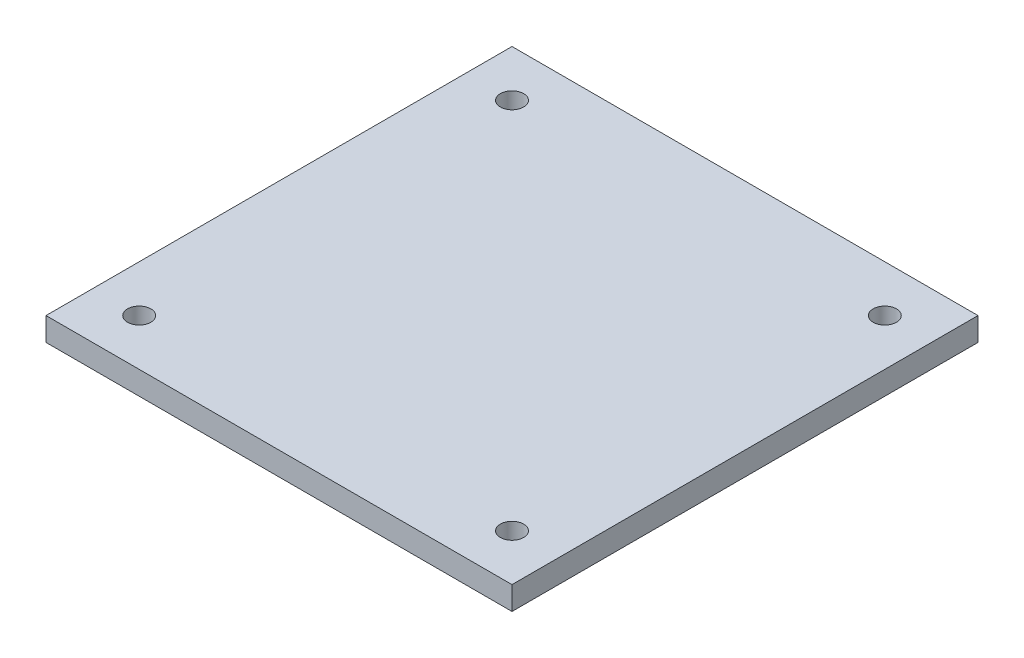
from build123d import *

# Parameters (mm, degrees)
SKETCH1_W           = 200
SKETCH1_H           = 200
BOSS_EXTRUDE1_DEPTH = 10
SKETCH2_R           = 5
CUT_EXTRUDE1_DEPTH  = 10


with BuildPart() as part:
    # Sketch1 → Boss-Extrude1 (new body)
    with BuildSketch(Plane(origin=(0, 0, 0), x_dir=(1, 0, 0), z_dir=(0, 1, 0))):
        Rectangle(SKETCH1_W, SKETCH1_H)
    extrude(amount=BOSS_EXTRUDE1_DEPTH)

    # Sketch2 → Cut-Extrude1 (cut)
    with BuildSketch(Plane(origin=(0, 10, 0), x_dir=(1, 0, 0), z_dir=(0, 1, 0))):
        with Locations((-80, 80)):
            Circle(SKETCH2_R)
        with Locations((80, 80)):
            Circle(SKETCH2_R)
        with Locations((80, -80)):
            Circle(SKETCH2_R)
        with Locations((-80, -80)):
            Circle(SKETCH2_R)
    extrude(amount=-CUT_EXTRUDE1_DEPTH, mode=Mode.SUBTRACT)


solid = part.part
